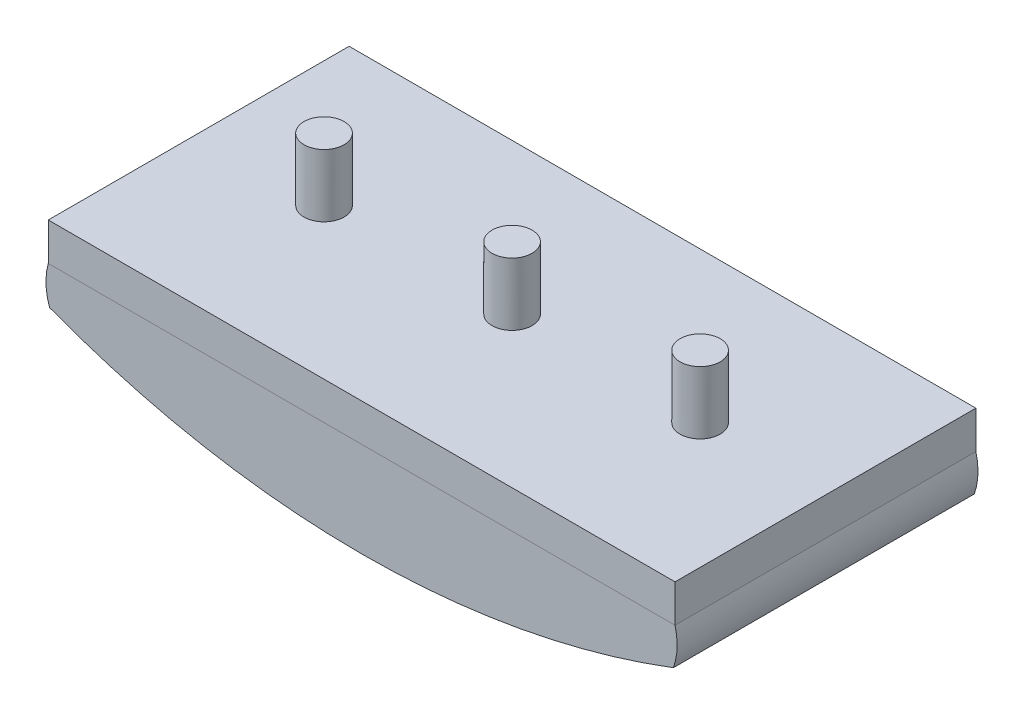
from build123d import *

# Parameters (mm, degrees)
SKETCH1_W           = 50
SKETCH1_H           = 24
BOSS_EXTRUDE1_DEPTH = 3
SKETCH2_R           = 1.6
BOSS_EXTRUDE2_DEPTH = 5
BOSS_EXTRUDE3_DEPTH = 24


with BuildPart() as part:
    # Sketch1 → Boss-Extrude1 (new body)
    with BuildSketch(Plane(origin=(0, 0, 0), x_dir=(1, 0, 0), z_dir=(0, 1, 0))):
        with Locations((25, 12)):
            Rectangle(SKETCH1_W, SKETCH1_H)
    extrude(amount=BOSS_EXTRUDE1_DEPTH)

    # Sketch2 → Boss-Extrude2 (add)
    with BuildSketch(Plane(origin=(0, 3, 0), x_dir=(1, 0, 0), z_dir=(0, 1, 0))):
        with Locations((10, 12)):
            Circle(SKETCH2_R)
        with Locations((25, 12)):
            Circle(SKETCH2_R)
        with Locations((40, 12)):
            Circle(SKETCH2_R)
    extrude(amount=BOSS_EXTRUDE2_DEPTH)


with BuildPart() as body_2:
    # Sketch4 → Boss-Extrude3 (new body)
    with BuildSketch(Plane(origin=(0, 0, -24), x_dir=(-1, 0, 0), z_dir=(0, 0, -1))):
        with BuildLine():
            Line((0, 0), (-50, 0))
            ThreePointArc((-50, 0), (-50.164079249, -1.510214747), (-49.867076753, -3))
            ThreePointArc((-49.867076753, -3), (-24.984514614, -7.571733162), (-0.101952476, -3))
            ThreePointArc((-0.101952476, -3), (0.179467134, -1.507831424), (0, 0))
        make_face()
    extrude(amount=-BOSS_EXTRUDE3_DEPTH)


solid = Compound([part.part, body_2.part])
